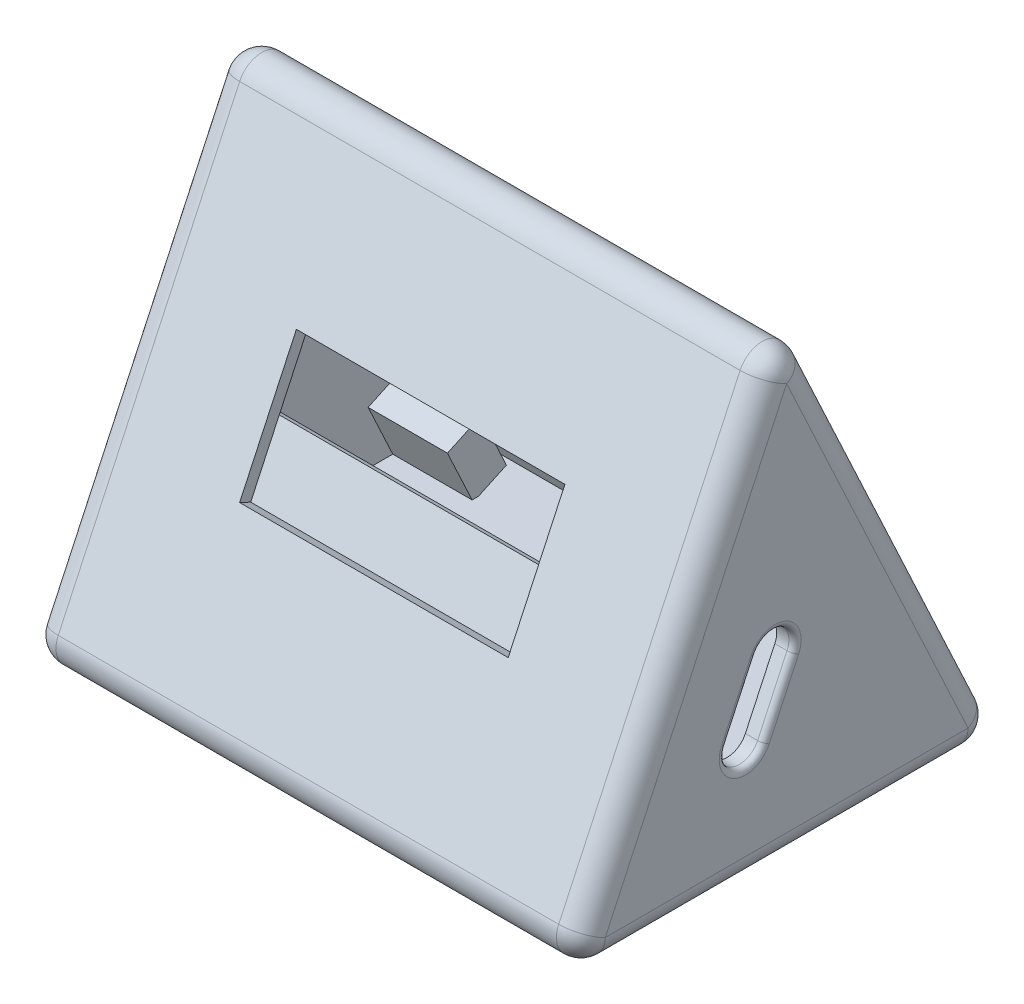
from build123d import *

# Parameters (mm, degrees)
EXTRUDE_1_DEPTH                  = 22.5
SKETCH_2_W                       = 22
SKETCH_2_H                       = 11
CUT_EXTRUDE_1_DEPTH              = 1
CUT_EXTRUDE_2_DEPTH              = 1.5
CUT_EXTRUDE_3_DEPTH              = 21
SKETCH_5_W                       = 39
SKETCH_5_H                       = 30.591628496
CUT_EXTRUDE_4_DEPTH              = 1.5
CUT_EXTRUDE_5_DEPTH              = 2
SKETCH_9_W                       = 4
SKETCH_9_H                       = 4
EXTRUDE_2_DEPTH                  = 5
CUT_EXTRUDE_6_DEPTH              = 5
EXTRUDE_3_DEPTH                  = 8
EXTRUDE_4_DEPTH                  = 8
HOLE_WIZARD_M2_3_D               = 1.6
HOLE_WIZARD_M2_3_DEPTH           = 2.5
HOLE_WIZARD_M2_3_TIP             = 0.480688495
HOLE_WIZARD_M2_3_ON_FACE_2_D     = 1.6
HOLE_WIZARD_M2_3_ON_FACE_2_DEPTH = 2.5
HOLE_WIZARD_M2_3_ON_FACE_2_TIP   = 0.480688495
HOLE_WIZARD_M2_5_D               = 1.6
HOLE_WIZARD_M2_5_DEPTH           = 2.5
HOLE_WIZARD_M2_5_TIP             = 0.480688495
EXTRUDE_6_DEPTH                  = 8
EXTRUDE_7_DEPTH                  = 8
HOLE_WIZARD_M2_7_D               = 1.6
HOLE_WIZARD_M2_7_DEPTH           = 2.5
HOLE_WIZARD_M2_7_TIP             = 0.480688495
HOLE_WIZARD_M2_7_ON_FACE_2_D     = 1.6
HOLE_WIZARD_M2_7_ON_FACE_2_DEPTH = 2.5
HOLE_WIZARD_M2_7_ON_FACE_2_TIP   = 0.480688495
HOLE_WIZARD_M2_11_D              = 1.6
HOLE_WIZARD_M2_11_DEPTH          = 3
HOLE_WIZARD_M2_11_TIP            = 0.480688495
FILLET_2_R                       = 2
FILLET_3_R                       = 0.5


with BuildPart() as part:
    # 草图1 → 凸台-拉伸1 (new body, symmetric)
    with BuildSketch(Plane(origin=(0, 0, 0), x_dir=(0, 0, -1), z_dir=(1, 0, 0))):
        Polygon((18, 0), (-18, 0), (0, 38.601124569), align=None)
    extrude(amount=EXTRUDE_1_DEPTH, both=True)

    # 草图2 → 切除-拉伸1 (cut)
    with BuildSketch(Plane(origin=(0, 6.894399988, 14.785088487), x_dir=(1, 0, 0), z_dir=(0, 0.422618262, 0.906307787))):
        with Locations((0, 13.713818509)):
            Rectangle(SKETCH_2_W, SKETCH_2_H)
    extrude(amount=-CUT_EXTRUDE_1_DEPTH, mode=Mode.SUBTRACT)

    # 草图3 → 切除-拉伸2 (cut)
    with BuildSketch(Plane(origin=(0, 6.471781726, 13.8787807), x_dir=(1, 0, 0), z_dir=(0, 0.422618262, 0.906307787))):
        Polygon((0, 5.236711419), (14, 5.236711419), (14, 13.686711419), (14, 28.358445695), (-21, 28.358445695), (-21, 5.236711419), align=None)
    extrude(amount=-CUT_EXTRUDE_2_DEPTH, mode=Mode.SUBTRACT)

    # 草图4 → 切除-拉伸3 (cut, symmetric)
    with BuildSketch(Plane(origin=(0, 0, 0), x_dir=(0, 0, -1), z_dir=(1, 0, 0))):
        Polygon((0.827533439, 33.277171007), (-13.990404756, 1.5), (15.645471634, 1.5), align=None)
    extrude(amount=CUT_EXTRUDE_3_DEPTH, both=True, mode=Mode.SUBTRACT)

    # 草图5 → 切除-拉伸4 (cut)
    with BuildSketch(Plane(origin=(0, 6.894399988, -14.785088487), x_dir=(-1, 0, 0), z_dir=(0, 0.422618262, -0.906307787))):
        with Locations((0, 11.688685537)):
            Rectangle(SKETCH_5_W, SKETCH_5_H)
    extrude(amount=-CUT_EXTRUDE_4_DEPTH, mode=Mode.SUBTRACT)

    # 草图6 → 切除-拉伸5 (cut)
    with BuildSketch(Plane(origin=(0, 5.626545203, 12.066165126), x_dir=(-1, 0, 0), z_dir=(0, -0.422618262, -0.906307787))):
        Polygon((-21, 13.204797954), (14.153696271, 13.204797954), (14.153696271, 10.359263572), (21, 10.359263572), (21, 29.984499785), (-21, 29.984499785), align=None)
    extrude(amount=-CUT_EXTRUDE_5_DEPTH, mode=Mode.SUBTRACT)

    # 草图9 → 凸台-拉伸2 (add)
    with BuildSketch(Plane(origin=(0, 4.527737722, 9.70976488), x_dir=(-1, 0, 0), z_dir=(0, -0.422618262, -0.906307787))):
        with Locations((-17.995066385, 20.221063534)):
            Rectangle(SKETCH_9_W, SKETCH_9_H)
        with Locations((11.604933615, -0.378936466)):
            Rectangle(SKETCH_9_W, SKETCH_9_H)
    extrude(amount=-EXTRUDE_2_DEPTH)

    # 草图12 → 切除-拉伸6 (cut)
    with BuildSketch(Plane(origin=(22.5, 0, 0), x_dir=(0, 0, -1), z_dir=(1, 0, 0))):
        with BuildLine():
            Line((-4.868770405, 10.635313289), (-2.459846313, 15.801267675))
            ThreePointArc((-2.459846313, 15.801267675), (-0.267118332, 16.599355392), (0.530969385, 14.406627411))
            Line((0.530969385, 14.406627411), (-1.877954707, 9.240673025))
            ThreePointArc((-1.877954707, 9.240673025), (-4.070682688, 8.442585308), (-4.868770405, 10.635313289))
        make_face()
    extrude(amount=-CUT_EXTRUDE_6_DEPTH, mode=Mode.SUBTRACT)

    # 草图14 → 凸台-拉伸3 (add)
    with BuildSketch(Plane.ZY.offset(22.5)):
        Polygon((-1.120034816, 30.283698198), (-3.233126124, 25.752159263), (-0.514202763, 24.484304477), (1.598888545, 29.015843413), align=None)
    extrude(amount=-EXTRUDE_3_DEPTH)

    # 草图15 → 凸台-拉伸4 (add)
    with BuildSketch(Plane(origin=(22.5, 0, 0), x_dir=(0, 0, -1), z_dir=(1, 0, 0))):
        Polygon((14.043757485, 2.568685494), (11.324834124, 1.300830709), (9.211742816, 5.832369644), (11.930666177, 7.100224429), align=None)
    extrude(amount=-EXTRUDE_4_DEPTH)

    # M2 螺纹孔3
    with Locations(Plane(origin=(17, 4.834454961, -12.987211831), x_dir=(0, -0.906307787, -0.422618262), z_dir=(0, 0.422618262, -0.906307787))):
        with Locations((0, 0)):
            Hole(HOLE_WIZARD_M2_3_D / 2, depth=HOLE_WIZARD_M2_3_DEPTH)
            with Locations((0, 0, -(HOLE_WIZARD_M2_3_DEPTH + HOLE_WIZARD_M2_3_TIP / 2))):  # 118° drill point
                Cone(0, HOLE_WIZARD_M2_3_D / 2, HOLE_WIZARD_M2_3_TIP, mode=Mode.SUBTRACT)

    # M2 螺纹孔3 on face 2
    with Locations(Plane(origin=(-17, 28.023137941, -2.174151375), x_dir=(0, -0.906307925, -0.422617965), z_dir=(0, 0.422617965, -0.906307925))):
        with Locations((1e-09, 0)):
            Hole(HOLE_WIZARD_M2_3_ON_FACE_2_D / 2, depth=HOLE_WIZARD_M2_3_ON_FACE_2_DEPTH)
            with Locations((0, 0, -(HOLE_WIZARD_M2_3_ON_FACE_2_DEPTH + HOLE_WIZARD_M2_3_ON_FACE_2_TIP / 2))):  # 118° drill point
                Cone(0, HOLE_WIZARD_M2_3_ON_FACE_2_D / 2, HOLE_WIZARD_M2_3_ON_FACE_2_TIP, mode=Mode.SUBTRACT)

    # M2 螺纹孔5
    with Locations(Plane(origin=(17.995066385, 22.854245065, 1.163974158), x_dir=(0, -0.906307787, 0.422618262), z_dir=(0, -0.422618262, -0.906307787))):
        with Locations((0, 0)):
            Hole(HOLE_WIZARD_M2_5_D / 2, depth=HOLE_WIZARD_M2_5_DEPTH)
            with Locations((0, 0, -(HOLE_WIZARD_M2_5_DEPTH + HOLE_WIZARD_M2_5_TIP / 2))):  # 118° drill point
                Cone(0, HOLE_WIZARD_M2_5_D / 2, HOLE_WIZARD_M2_5_TIP, mode=Mode.SUBTRACT)

    # 草图27 → 凸台-拉伸6 (add)
    with BuildSketch(Plane.ZY.offset(22.5)):
        Polygon((-14.043757485, 2.568685494), (-11.930666177, 7.100224429), (-9.211742816, 5.832369644), (-11.324834124, 1.300830709), align=None)
    extrude(amount=-EXTRUDE_6_DEPTH)

    # 草图28 → 凸台-拉伸7 (add)
    with BuildSketch(Plane(origin=(22.5, 0, 0), x_dir=(0, 0, -1), z_dir=(1, 0, 0))):
        Polygon((1.115176626, 30.294116619), (-1.603746735, 29.026261833), (0.509344574, 24.494722898), (3.228267935, 25.762577683), align=None)
    extrude(amount=-EXTRUDE_7_DEPTH)

    # M2 螺纹孔7
    with Locations(Plane(origin=(17, 28.028347151, -2.171722281), x_dir=(0, -0.906307787, -0.422618262), z_dir=(0, 0.422618262, -0.906307787))):
        with Locations((0, 0)):
            Hole(HOLE_WIZARD_M2_7_D / 2, depth=HOLE_WIZARD_M2_7_DEPTH)
            with Locations((0, 0, -(HOLE_WIZARD_M2_7_DEPTH + HOLE_WIZARD_M2_7_TIP / 2))):  # 118° drill point
                Cone(0, HOLE_WIZARD_M2_7_D / 2, HOLE_WIZARD_M2_7_TIP, mode=Mode.SUBTRACT)

    # M2 螺纹孔7 on face 2
    with Locations(Plane(origin=(-17, 4.834454961, -12.987211831), x_dir=(0, -0.906307925, -0.422617965), z_dir=(0, 0.422617965, -0.906307925))):
        with Locations((0, 0)):
            Hole(HOLE_WIZARD_M2_7_ON_FACE_2_D / 2, depth=HOLE_WIZARD_M2_7_ON_FACE_2_DEPTH)
            with Locations((0, 0, -(HOLE_WIZARD_M2_7_ON_FACE_2_DEPTH + HOLE_WIZARD_M2_7_ON_FACE_2_TIP / 2))):  # 118° drill point
                Cone(0, HOLE_WIZARD_M2_7_ON_FACE_2_D / 2, HOLE_WIZARD_M2_7_ON_FACE_2_TIP, mode=Mode.SUBTRACT)

    # M2 螺纹孔11
    with Locations(Plane(origin=(0, 0, 9), x_dir=(1, 0, 0), z_dir=(0, 0, -1))):
        with Locations((-11.604933615, -4.184304653)):
            Hole(HOLE_WIZARD_M2_11_D / 2, depth=HOLE_WIZARD_M2_11_DEPTH)
            with Locations((0, 0, -(HOLE_WIZARD_M2_11_DEPTH + HOLE_WIZARD_M2_11_TIP / 2))):  # 118° drill point
                Cone(0, HOLE_WIZARD_M2_11_D / 2, HOLE_WIZARD_M2_11_TIP, mode=Mode.SUBTRACT)

    # 圆角2
    fillet_2_edges = [part.edges().sort_by_distance(p)[0] for p in [
        (22.5, 0, 0),
        (-22.5, 0, 0),
        (22.5, 19.300562285, -9),
        (-22.5, 19.300562285, 9),
        (-22.5, 19.300562285, -9),
        (0, 0, -18),
        (0, 0, 18),
        (0, 38.601124569, 0),
        (22.5, 19.300562285, 9),
    ]]
    fillet(fillet_2_edges, radius=FILLET_2_R)

    # 圆角3
    fillet_3_edges = [part.edges().sort_by_distance(p)[0] for p in [
        (22.5, 8.442585308, 4.070682688),
        (22.5, 11.823650218, 0.673492661),
        (22.5, 16.599355392, 0.267118332),
        (22.5, 13.218290482, 3.664308359),
    ]]
    fillet(fillet_3_edges, radius=FILLET_3_R)


solid = part.part
